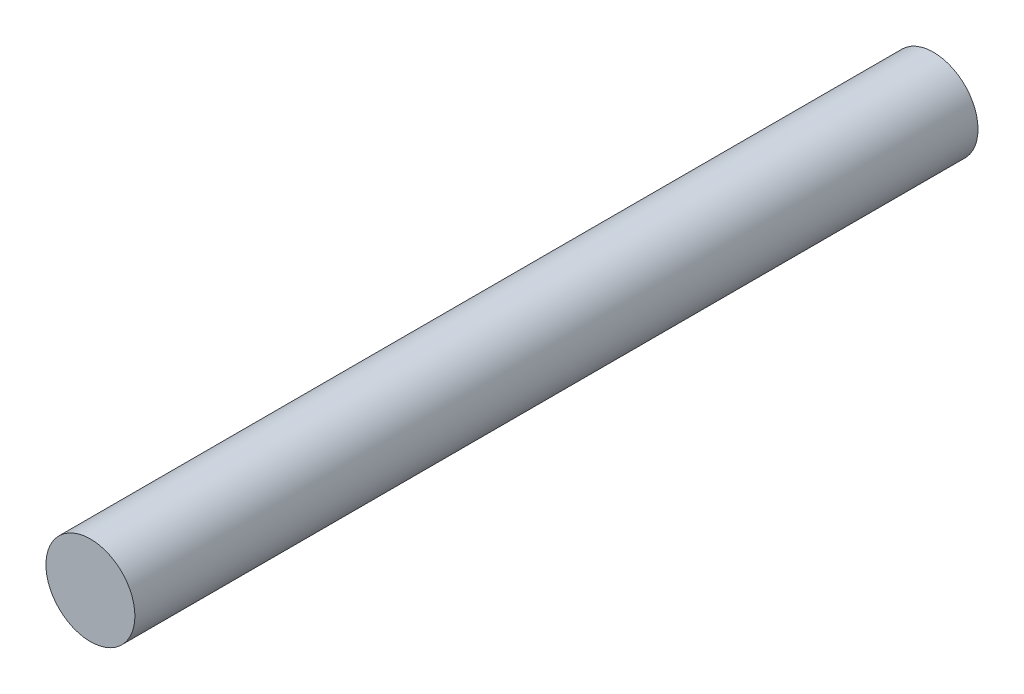
from build123d import *

# Parameters (mm, degrees)
SKETCH1_R           = 4.75
BOSS_EXTRUDE1_DEPTH = 90


with BuildPart() as part:
    # Sketch1 → Boss-Extrude1 (new body)
    with BuildSketch(Plane.XY):
        Circle(SKETCH1_R)
    extrude(amount=BOSS_EXTRUDE1_DEPTH)


solid = part.part
